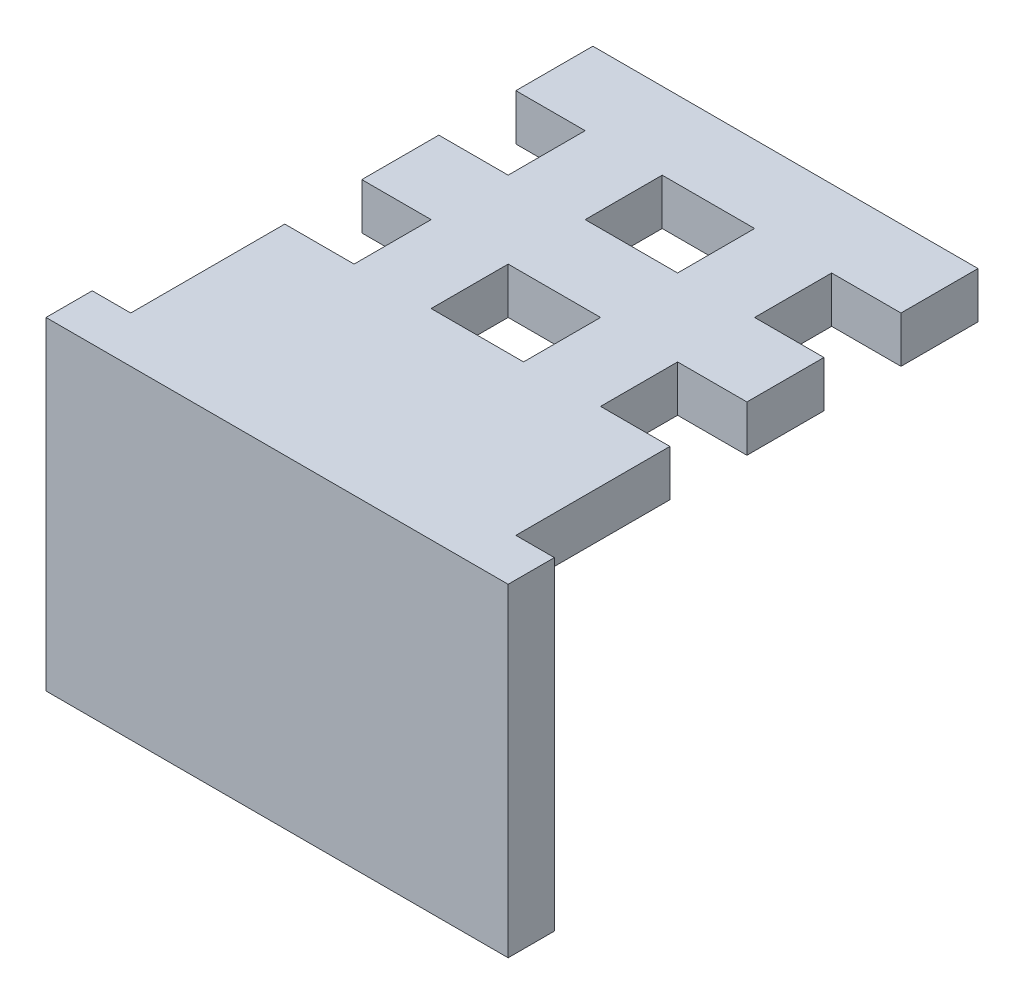
from build123d import *

# Parameters (mm, degrees)
SKETCH1_W           = 300
SKETCH1_H           = 380
BOSS_EXTRUDE1_DEPTH = 30
SKETCH3_W           = 250
SKETCH3_H           = 30
BOSS_EXTRUDE2_DEPTH = 100
BOSS_EXTRUDE3_START = 150
SKETCH3_2_W         = 250
SKETCH3_2_H         = 30
BOSS_EXTRUDE3_DEPTH = 50
BOSS_EXTRUDE4_START = 250
SKETCH3_3_W         = 250
SKETCH3_3_H         = 30
BOSS_EXTRUDE4_DEPTH = 50
BOSS_EXTRUDE5_REACH = 303.662
SKETCH4_W           = 50
SKETCH4_H           = 30
BOSS_EXTRUDE6_START = -50
SKETCH4_2_W         = 50
SKETCH4_2_H         = 30
BOSS_EXTRUDE6_DEPTH = 50
SKETCH5_R           = 10
CUT_EXTRUDE1_DEPTH  = 10
SKETCH6_R           = 5
CUT_EXTRUDE2_DEPTH  = 10
SKETCH7_W           = 300
SKETCH7_H           = 170
CUT_EXTRUDE3_DEPTH  = 30


with BuildPart() as part:
    # Sketch1 → Boss-Extrude1 (new body)
    with BuildSketch(Plane.XY):
        Rectangle(SKETCH1_W, SKETCH1_H)
    extrude(amount=BOSS_EXTRUDE1_DEPTH)

    # Sketch3 → Boss-Extrude2 (add)
    with BuildSketch(Plane(origin=(0, 0, 0), x_dir=(-1, 0, 0), z_dir=(0, 0, -1))):
        with Locations((0, 175)):
            Rectangle(SKETCH3_W, SKETCH3_H)
    extrude(amount=BOSS_EXTRUDE2_DEPTH)

    # Sketch4 → Boss-Extrude5 (add, up to next)
    with BuildSketch(Plane.XY.offset(-150), mode=Mode.PRIVATE) as boss_extrude5_sk1:
        with Locations((-55, 175)):
            Rectangle(SKETCH4_W, SKETCH4_H)
    boss_extrude5_tool1 = extrude(boss_extrude5_sk1.sketch, amount=BOSS_EXTRUDE5_REACH, mode=Mode.PRIVATE) - part.part
    # Sketch4 → Boss-Extrude5 (add, up to next)
    with BuildSketch(Plane.XY.offset(-150), mode=Mode.PRIVATE) as boss_extrude5_sk2:
        with Locations((55, 175)):
            Rectangle(SKETCH4_W, SKETCH4_H)
    boss_extrude5_tool2 = extrude(boss_extrude5_sk2.sketch, amount=BOSS_EXTRUDE5_REACH, mode=Mode.PRIVATE) - part.part


with BuildPart() as body_2:
    # Sketch3_2 → Boss-Extrude3 (new body)
    with BuildSketch(Plane(origin=(0, 0, 0), x_dir=(-1, 0, 0), z_dir=(0, 0, -1)).offset(BOSS_EXTRUDE3_START)):
        with Locations((0, 175)):
            Rectangle(SKETCH3_2_W, SKETCH3_2_H)
    extrude(amount=BOSS_EXTRUDE3_DEPTH)


with BuildPart() as body_3:
    # Sketch3_3 → Boss-Extrude4 (new body)
    with BuildSketch(Plane(origin=(0, 0, 0), x_dir=(-1, 0, 0), z_dir=(0, 0, -1)).offset(BOSS_EXTRUDE4_START)):
        with Locations((0, 175)):
            Rectangle(SKETCH3_3_W, SKETCH3_3_H)
    extrude(amount=BOSS_EXTRUDE4_DEPTH)


with BuildPart() as part_1:
    add(part.part)

    add(body_2.part)  # Boss-Extrude5 merges body 2
    add(boss_extrude5_tool1.solids().sort_by_distance((-55, 175, -150))[0])
    add(boss_extrude5_tool2.solids().sort_by_distance((55, 175, -150))[0])


    add(body_3.part)  # Boss-Extrude6 merges body 3
    # Sketch4_2 → Boss-Extrude6 (add)
    with BuildSketch(Plane.XY.offset(-150).offset(BOSS_EXTRUDE6_START)):
        with Locations((-55, 175)):
            Rectangle(SKETCH4_2_W, SKETCH4_2_H)
        with Locations((55, 175)):
            Rectangle(SKETCH4_2_W, SKETCH4_2_H)
    extrude(amount=-BOSS_EXTRUDE6_DEPTH)

    # Sketch5 → Cut-Extrude1 (cut)
    with BuildSketch(Plane.XZ.offset(-160)):
        with Locations((-80, -275)):
            Circle(SKETCH5_R)
        with Locations((80, -275)):
            Circle(SKETCH5_R)
        with Locations((0, -75)):
            Circle(SKETCH5_R)
    extrude(amount=-CUT_EXTRUDE1_DEPTH, mode=Mode.SUBTRACT)

    # Sketch6 → Cut-Extrude2 (cut)
    with BuildSketch(Plane(origin=(0, 0, 0), x_dir=(-1, 0, 0), z_dir=(0, 0, -1))):
        with Locations((-45, 40)):
            Circle(SKETCH6_R)
        with Locations((45, 40)):
            Circle(SKETCH6_R)
    extrude(amount=-CUT_EXTRUDE2_DEPTH, mode=Mode.SUBTRACT)

    # Sketch7 → Cut-Extrude3 (cut)
    with BuildSketch(Plane(origin=(0, 0, 0), x_dir=(-1, 0, 0), z_dir=(0, 0, -1))):
        with Locations((0, -105)):
            Rectangle(SKETCH7_W, SKETCH7_H)
    extrude(amount=-CUT_EXTRUDE3_DEPTH, mode=Mode.SUBTRACT)


solid = part_1.part
